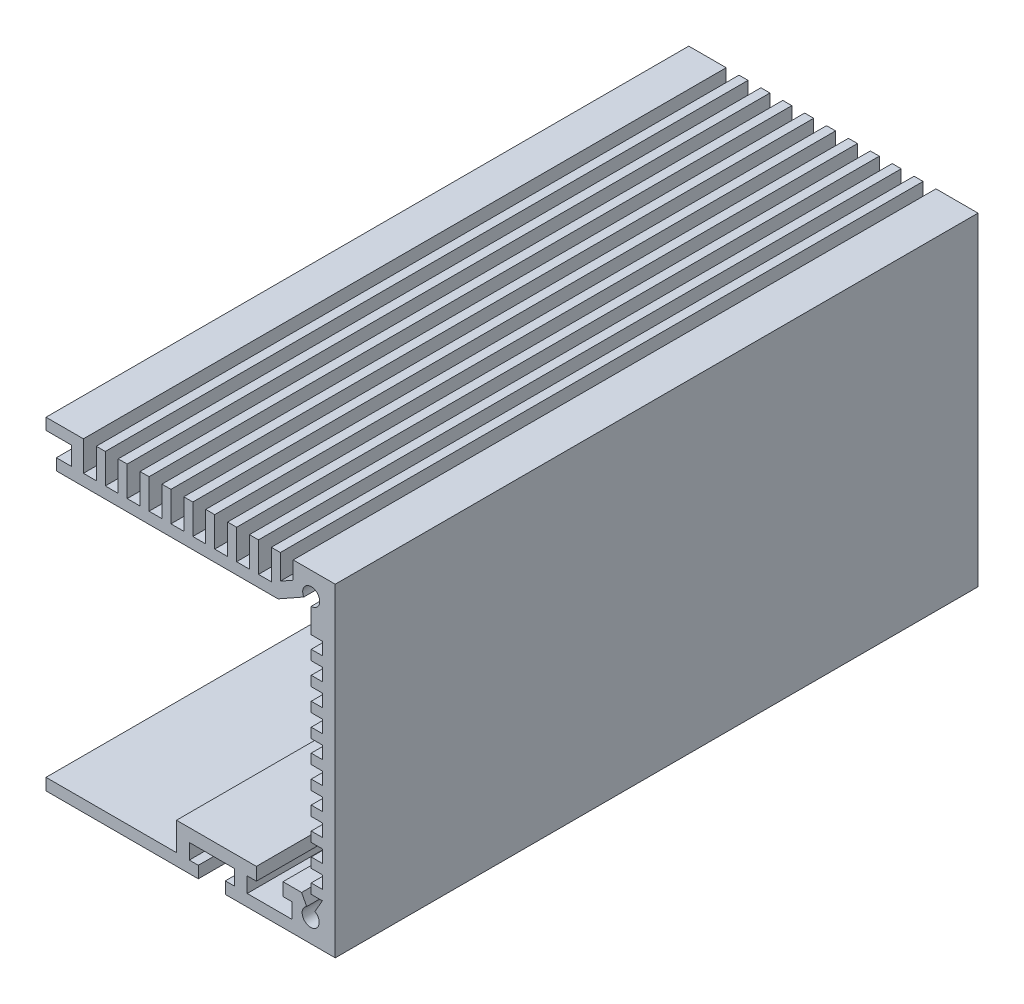
from build123d import *

# Parameters (mm, degrees)
BOSS_EXTRUDE1_DEPTH = 100


with BuildPart() as part:
    # Sketch2 → Boss-Extrude1 (new body)
    with BuildSketch(Plane(origin=(0, 0, 0), x_dir=(-1, 0, 0), z_dir=(0, 0, -1))):
        with BuildLine():
            Line((-81.1, 43.92), (-46.615, 43.92))
            Line((-46.615, 43.92), (-46.615, 45.7))
            Line((-46.615, 45.7), (-49, 45.7))
            Line((-49, 45.7), (-49, 48.57))
            Line((-49, 48.57), (-45, 48.57))
            Line((-45, 48.57), (-45, 50.35))
            Line((-45, 50.35), (-50.82, 50.35))
            Line((-50.82, 50.35), (-50.82, 45.7))
            Line((-50.82, 45.7), (-52.82, 45.7))
            Line((-52.82, 45.7), (-52.82, 50.35))
            Line((-52.82, 50.35), (-54.224444444, 50.35))
            Line((-54.224444444, 50.35), (-54.224444444, 45.7))
            Line((-54.224444444, 45.7), (-56.224444444, 45.7))
            Line((-56.224444444, 45.7), (-56.224444444, 50.35))
            Line((-56.224444444, 50.35), (-57.628888889, 50.35))
            Line((-57.628888889, 50.35), (-57.628888889, 45.7))
            Line((-57.628888889, 45.7), (-59.628888889, 45.7))
            Line((-59.628888889, 45.7), (-59.628888889, 50.35))
            Line((-59.628888889, 50.35), (-61.033333333, 50.35))
            Line((-61.033333333, 50.35), (-61.033333333, 45.7))
            Line((-61.033333333, 45.7), (-63.033333333, 45.7))
            Line((-63.033333333, 45.7), (-63.033333333, 50.35))
            Line((-63.033333333, 50.35), (-64.437777778, 50.35))
            Line((-64.437777778, 50.35), (-64.437777778, 45.7))
            Line((-64.437777778, 45.7), (-66.437777778, 45.7))
            Line((-66.437777778, 45.7), (-66.437777778, 50.35))
            Line((-66.437777778, 50.35), (-67.842222222, 50.35))
            Line((-67.842222222, 50.35), (-67.842222222, 45.7))
            Line((-67.842222222, 45.7), (-69.842222222, 45.7))
            Line((-69.842222222, 45.7), (-69.842222222, 50.35))
            Line((-69.842222222, 50.35), (-71.246666667, 50.35))
            Line((-71.246666667, 50.35), (-71.246666667, 45.7))
            Line((-71.246666667, 45.7), (-73.246666667, 45.7))
            Line((-73.246666667, 45.7), (-73.246666667, 50.35))
            Line((-73.246666667, 50.35), (-74.651111111, 50.35))
            Line((-74.651111111, 50.35), (-74.651111111, 45.7))
            Line((-74.651111111, 45.7), (-76.651111111, 45.7))
            Line((-76.651111111, 45.7), (-76.651111111, 50.35))
            Line((-76.651111111, 50.35), (-78.055555556, 50.35))
            Line((-78.055555556, 50.35), (-78.055555556, 45.7))
            Line((-78.055555556, 45.7), (-80.055555556, 45.7))
            Line((-80.055555556, 45.7), (-80.055555556, 50.35))
            Line((-80.055555556, 50.35), (-81.46, 50.35))
            Line((-81.46, 50.35), (-81.46, 46.490680448))
            Line((-81.46, 46.490680448), (-83.46, 47.61664944))
            Line((-83.46, 47.61664944), (-83.46, 50.35))
            Line((-83.46, 50.35), (-90, 50.35))
            Line((-90, 50.35), (-90, 0))
            Line((-90, 0), (-72.9, 0))
            Line((-72.9, 0), (-72.9, 1.83))
            Line((-72.9, 1.83), (-74.3, 1.83))
            Line((-74.3, 1.83), (-74.3, 4.2))
            Line((-74.3, 4.2), (-67.3, 4.2))
            Line((-67.3, 4.2), (-67.3, 1.83))
            Line((-67.3, 1.83), (-68.7, 1.83))
            Line((-68.7, 1.83), (-68.7, 0))
            Line((-68.7, 0), (-45, 0))
            Line((-45, 0), (-45, 1.83))
            Line((-45, 1.83), (-65.3, 1.83))
            Line((-65.3, 1.83), (-65.3, 6.2))
            Line((-65.3, 6.2), (-77.73, 6.2))
            Line((-77.73, 6.2), (-77.73, 4.2))
            Line((-77.73, 4.2), (-76.3, 4.2))
            Line((-76.3, 4.2), (-76.3, 1.83))
            Line((-76.3, 1.83), (-83.3, 1.83))
            Line((-83.3, 1.83), (-83.3, 4.2))
            Line((-83.3, 4.2), (-81.87, 4.2))
            Line((-81.87, 4.2), (-81.87, 6.2))
            Line((-81.87, 6.2), (-84.76556902, 6.2))
            Line((-84.76556902, 6.2), (-85.557358859, 4.697239063))
            ThreePointArc((-85.557358859, 4.697239063), (-86.149971444, 2.200236409), (-86.836478439, 4.673072852))
            Line((-86.836478439, 4.673072852), (-88, 6.6925))
            Line((-88, 6.6925), (-86.26, 6.6925))
            Line((-86.26, 6.6925), (-86.26, 8.23))
            Line((-86.26, 8.23), (-88, 8.23))
            Line((-88, 8.23), (-88, 10.19))
            Line((-88, 10.19), (-86.26, 10.19))
            Line((-86.26, 10.19), (-86.26, 11.7275))
            Line((-86.26, 11.7275), (-88, 11.7275))
            Line((-88, 11.7275), (-88, 13.6875))
            Line((-88, 13.6875), (-86.26, 13.6875))
            Line((-86.26, 13.6875), (-86.26, 15.225))
            Line((-86.26, 15.225), (-88, 15.225))
            Line((-88, 15.225), (-88, 17.185))
            Line((-88, 17.185), (-86.26, 17.185))
            Line((-86.26, 17.185), (-86.26, 18.7225))
            Line((-86.26, 18.7225), (-88, 18.7225))
            Line((-88, 18.7225), (-88, 20.6825))
            Line((-88, 20.6825), (-86.26, 20.6825))
            Line((-86.26, 20.6825), (-86.26, 22.22))
            Line((-86.26, 22.22), (-88, 22.22))
            Line((-88, 22.22), (-88, 24.18))
            Line((-88, 24.18), (-86.26, 24.18))
            Line((-86.26, 24.18), (-86.26, 25.7175))
            Line((-86.26, 25.7175), (-88, 25.7175))
            Line((-88, 25.7175), (-88, 27.6775))
            Line((-88, 27.6775), (-86.26, 27.6775))
            Line((-86.26, 27.6775), (-86.26, 29.215))
            Line((-86.26, 29.215), (-88, 29.215))
            Line((-88, 29.215), (-88, 31.175))
            Line((-88, 31.175), (-86.26, 31.175))
            Line((-86.26, 31.175), (-86.26, 32.7125))
            Line((-86.26, 32.7125), (-88, 32.7125))
            Line((-88, 32.7125), (-88, 34.6725))
            Line((-88, 34.6725), (-86.26, 34.6725))
            Line((-86.26, 34.6725), (-86.26, 36.21))
            Line((-86.26, 36.21), (-88, 36.21))
            Line((-88, 36.21), (-88, 38.17))
            Line((-88, 38.17), (-86.26, 38.17))
            Line((-86.26, 38.17), (-86.26, 39.7075))
            Line((-86.26, 39.7075), (-88, 39.7075))
            Line((-88, 39.7075), (-88, 41.6675))
            Line((-88, 41.6675), (-86.26, 41.6675))
            Line((-86.26, 41.6675), (-86.26, 45.5))
            ThreePointArc((-86.26, 45.5), (-86.92871037, 47.968875623), (-85.105401522, 46.174978958))
            Line((-85.105401522, 46.174978958), (-81.1, 43.92))
        make_face()
    extrude(amount=BOSS_EXTRUDE1_DEPTH)


solid = part.part
